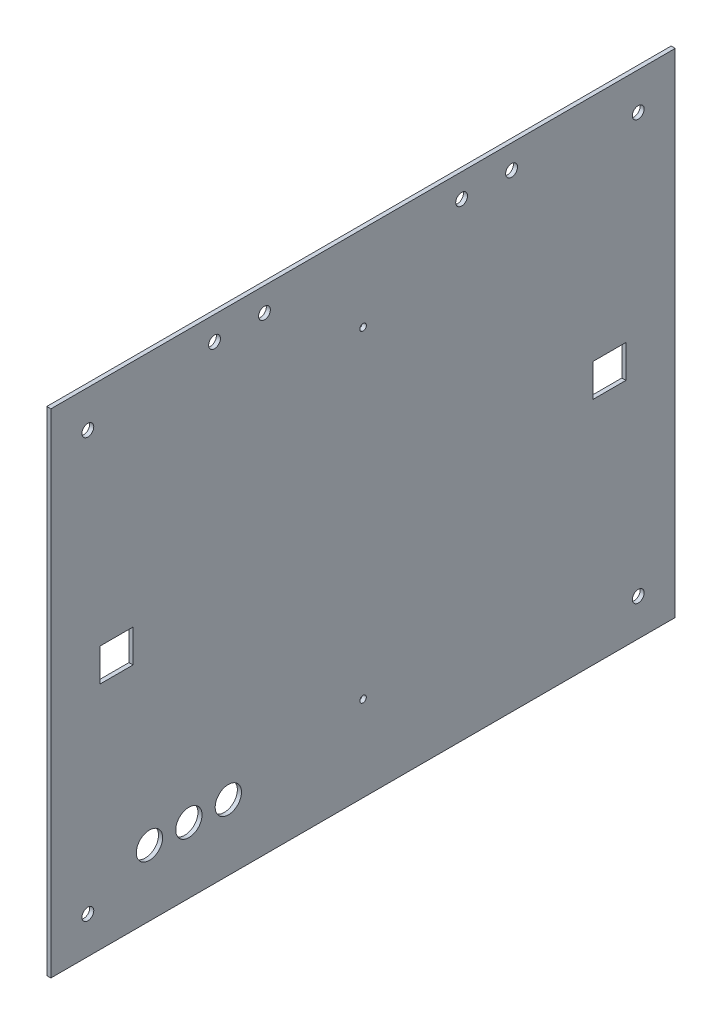
from build123d import *

# Parameters (mm, degrees)
SKETCH1_W                     = 241.3
SKETCH1_H                     = 190.5
MAIN_BODY_DEPTH               = 1.5875
SKETCH2_R                     = 2.286
BOLT_HOLES_DEPTH              = 2.5875
SKETCH3_R                     = 2.286
LOCKING_MECHANISM_HOLES_DEPTH = 2.5875
SKETCH4_W                     = 12.7
SKETCH4_H                     = 12.7
LED_HOLES_DEPTH               = 2.5875
SKETCH5_R                     = 1.27
LOGO_MOUNT_HOLES_DEPTH        = 2.5875
SKETCH6_R                     = 5.08
PANEL_MOUNT_LED_HOLE_DEPTH    = 2.5875


with BuildPart() as part:
    # Sketch1 → Main Body (new body)
    with BuildSketch(Plane(origin=(0, 0, 0), x_dir=(0, 0, -1), z_dir=(1, 0, 0))):
        with Locations((120.65, 95.25)):
            Rectangle(SKETCH1_W, SKETCH1_H)
    extrude(amount=MAIN_BODY_DEPTH)

    # Sketch2 → Bolt Holes (cut, through all)
    with BuildSketch(Plane(origin=(1.5875, 0, 0), x_dir=(0, 0, -1), z_dir=(1, 0, 0))):
        with Locations((227.0125, 14.2875)):
            Circle(SKETCH2_R)
        with Locations((227.0125, 176.2125)):
            Circle(SKETCH2_R)
        with Locations((14.2875, 14.2875)):
            Circle(SKETCH2_R)
        with Locations((14.2875, 176.2125)):
            Circle(SKETCH2_R)
    extrude(amount=-BOLT_HOLES_DEPTH, mode=Mode.SUBTRACT)

    # Sketch3 → Locking Mechanism Holes (cut, through all)
    with BuildSketch(Plane(origin=(1.5875, 0, 0), x_dir=(0, 0, -1), z_dir=(1, 0, 0))):
        with Locations((63.246, 181.2925)):
            Circle(SKETCH3_R)
        with Locations((82.55, 181.2925)):
            Circle(SKETCH3_R)
        with Locations((158.75, 181.2925)):
            Circle(SKETCH3_R)
        with Locations((178.054, 181.2925)):
            Circle(SKETCH3_R)
    extrude(amount=-LOCKING_MECHANISM_HOLES_DEPTH, mode=Mode.SUBTRACT)

    # Sketch4 → LED Holes (cut, through all)
    with BuildSketch(Plane(origin=(1.5875, 0, 0), x_dir=(0, 0, -1), z_dir=(1, 0, 0))):
        with Locations((25.4, 95.25)):
            Rectangle(SKETCH4_W, SKETCH4_H)
        with Locations((215.9, 95.25)):
            Rectangle(SKETCH4_W, SKETCH4_H)
    extrude(amount=-LED_HOLES_DEPTH, mode=Mode.SUBTRACT)

    # Sketch5 → Logo Mount Holes (cut, through all)
    with BuildSketch(Plane(origin=(1.5875, 0, 0), x_dir=(0, 0, -1), z_dir=(1, 0, 0))):
        with Locations((120.65, 157.48)):
            Circle(SKETCH5_R)
        with Locations((120.65, 33.02)):
            Circle(SKETCH5_R)
    extrude(amount=-LOGO_MOUNT_HOLES_DEPTH, mode=Mode.SUBTRACT)

    # Sketch6 → Panel Mount LED Hole (cut, through all)
    with BuildSketch(Plane(origin=(1.5875, 0, 0), x_dir=(0, 0, -1), z_dir=(1, 0, 0))):
        with Locations((38.1, 25.4)):
            Circle(SKETCH6_R)
        with Locations((53.34, 25.4)):
            Circle(SKETCH6_R)
        with Locations((68.58, 25.4)):
            Circle(SKETCH6_R)
    extrude(amount=-PANEL_MOUNT_LED_HOLE_DEPTH, mode=Mode.SUBTRACT)


solid = part.part
